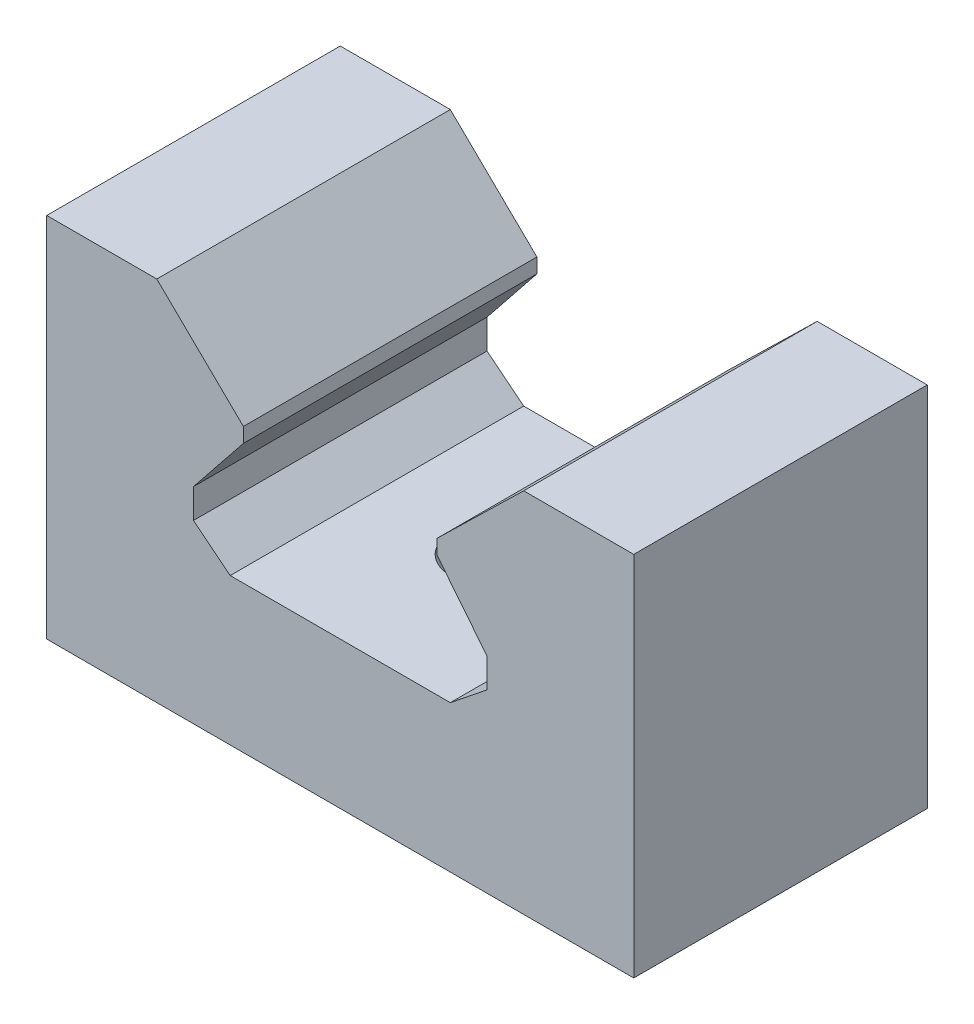
from build123d import *

# Parameters (mm, degrees)
SKETCH_1_W               = 40
SKETCH_1_H               = 25
EXTRUDE_1_DEPTH          = 20
CUT_EXTRUDE_1_DEPTH      = 1
CUT_EXTRUDE_1_DEPTH_BACK = 20
HOLE_WIZARD_M6_1_D       = 5
HOLE_WIZARD_M6_1_DEPTH   = 18
HOLE_WIZARD_M6_1_TIP     = 1.502151548


with BuildPart() as part:
    # 草图1 → 凸台-拉伸1 (new body)
    with BuildSketch(Plane.XY):
        Rectangle(SKETCH_1_W, SKETCH_1_H)
    extrude(amount=EXTRUDE_1_DEPTH)

    # 草图2 → 切除-拉伸1 (cut, two sides)
    with BuildSketch(Plane(origin=(0, 0, 0), x_dir=(-1, 0, 0), z_dir=(0, 0, -1))) as cut_extrude_1_sk:
        Polygon((-78.390332326, 76.715154385), (-12.5, 12.5), (-6.6, 6.75), (-6.6, 5.75), (-10, 1.5), (-10, -0.5), (-7.5, -2.5), (7.5, -2.5), (10, -0.5), (10, 1.5), (6.6, 5.75), (6.6, 6.75), (12.5, 12.5), (78.390332326, 76.715154385), (78.390332326, 260.727349054), (-78.390332326, 260.727349054), align=None)
    extrude(amount=CUT_EXTRUDE_1_DEPTH, mode=Mode.SUBTRACT)
    extrude(cut_extrude_1_sk.sketch, amount=-CUT_EXTRUDE_1_DEPTH_BACK, mode=Mode.SUBTRACT)

    # M6 螺纹孔1
    with Locations(Plane(origin=(0, -12.5, 0), x_dir=(-1, 0, 0), z_dir=(0, -1, 0))):
        with Locations((0, -10)):
            Hole(HOLE_WIZARD_M6_1_D / 2, depth=HOLE_WIZARD_M6_1_DEPTH)
            with Locations((0, 0, -(HOLE_WIZARD_M6_1_DEPTH + HOLE_WIZARD_M6_1_TIP / 2))):  # 118° drill point
                Cone(0, HOLE_WIZARD_M6_1_D / 2, HOLE_WIZARD_M6_1_TIP, mode=Mode.SUBTRACT)


solid = part.part
